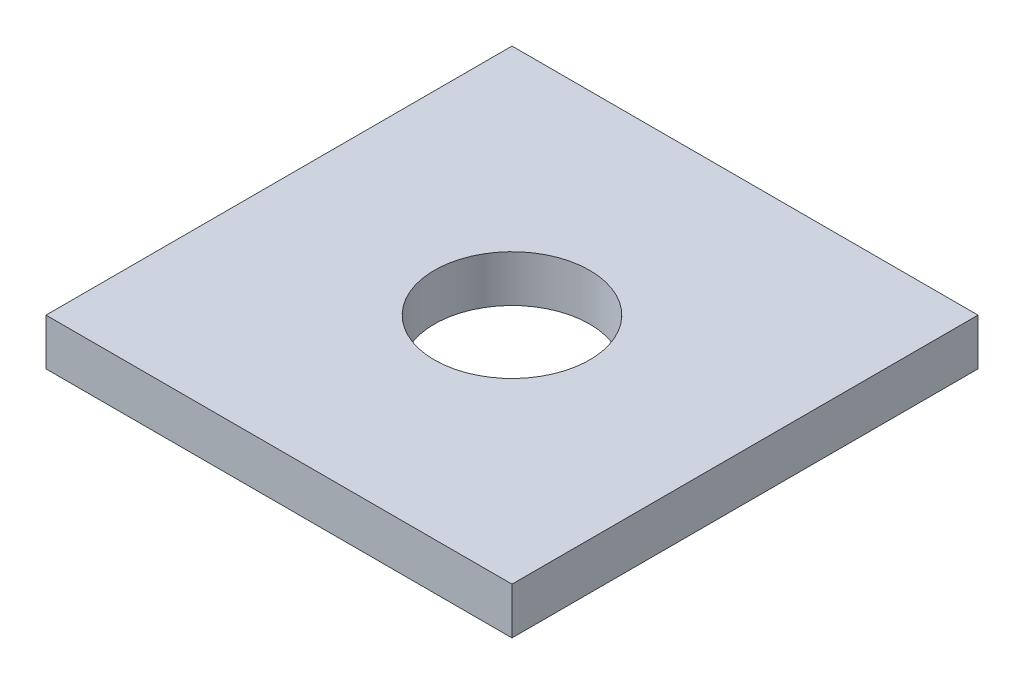
from build123d import *

# Parameters (mm, degrees)
SKETCH1_W           = 30
SKETCH1_H           = 30
SKETCH1_R           = 5
BOSS_EXTRUDE1_DEPTH = 3


with BuildPart() as part:
    # Sketch1 → Boss-Extrude1 (new body)
    with BuildSketch(Plane(origin=(0, 0, 0), x_dir=(1, 0, 0), z_dir=(0, 1, 0))):
        Rectangle(SKETCH1_W, SKETCH1_H)
        Circle(SKETCH1_R, mode=Mode.SUBTRACT)
    extrude(amount=BOSS_EXTRUDE1_DEPTH)


solid = part.part
